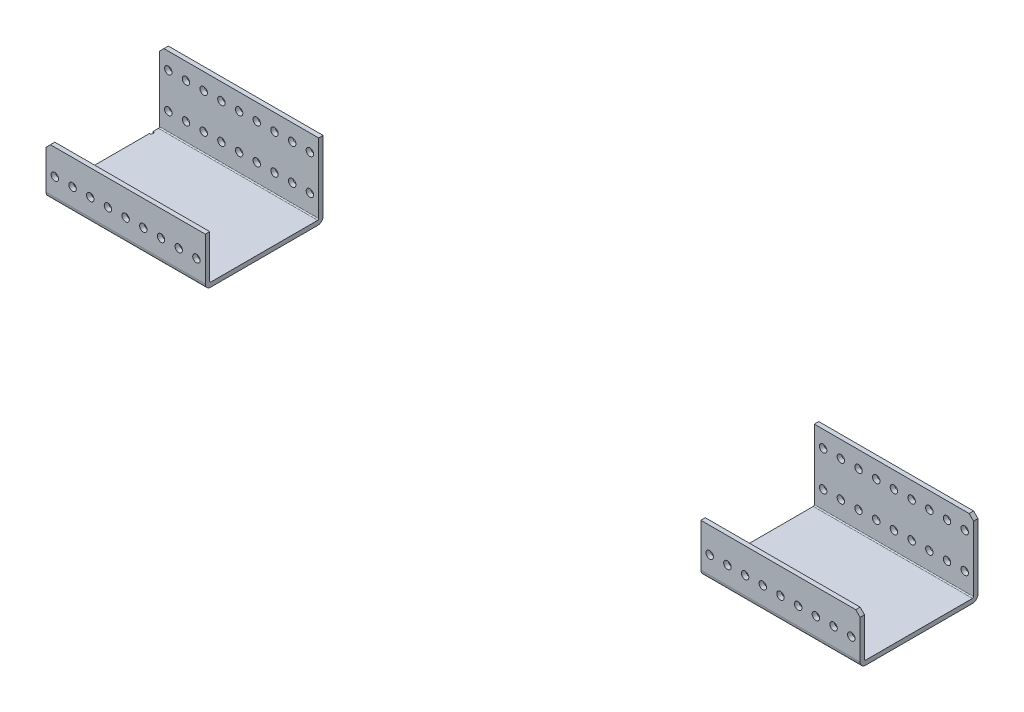
from build123d import *

# Parameters (mm, degrees)
SKETCH1_W                = 584.2
SKETCH1_H                = 84.582
BOSS_EXTRUDE1_DEPTH      = 34.925
SKETCH2_W                = 81.407
SKETCH2_H                = 31.75
CUT_EXTRUDE1_DEPTH       = 585.2
SKETCH3_W                = 584.2
SKETCH3_H                = 3.175
BOSS_EXTRUDE2_DEPTH      = 50.8
M2_CLEARANCE_HOLE1_D     = 2.54
M2_CLEARANCE_HOLE1_DEPTH = 3.175
M5_CLEARANCE_HOLE1_D     = 5.334
M5_CLEARANCE_HOLE1_DEPTH = 84.582
CHAMFER1_SIZE            = 3.175
FILLET1_R                = 0.762
FILLET2_R                = 3.937
SKETCH9_W                = 355.6
SKETCH9_H                = 96.804801105
CUT_EXTRUDE2_DEPTH       = 85.582


with BuildPart() as part:
    # Sketch1 → Boss-Extrude1 (new body)
    with BuildSketch(Plane(origin=(0, 57.816398039, 0), x_dir=(1, 0, 0), z_dir=(0, 1, 0))):
        with Locations((195.998031467, -103.269491579)):
            Rectangle(SKETCH1_W, SKETCH1_H)
    extrude(amount=-BOSS_EXTRUDE1_DEPTH)

    # Sketch2 → Cut-Extrude1 (cut, through all)
    with BuildSketch(Plane(origin=(488.098031467, 0, 0), x_dir=(0, 0, -1), z_dir=(1, 0, 0))):
        with Locations((-101.681991579, 41.941398039)):
            Rectangle(SKETCH2_W, SKETCH2_H)
    extrude(amount=-CUT_EXTRUDE1_DEPTH, mode=Mode.SUBTRACT)

    # Sketch3 → Boss-Extrude2 (add)
    with BuildSketch(Plane(origin=(0, 26.066398039, 0), x_dir=(-1, 0, 0), z_dir=(0, 1, 0))):
        with Locations((-195.998031467, 62.565991579)):
            Rectangle(SKETCH3_W, SKETCH3_H)
    extrude(amount=BOSS_EXTRUDE2_DEPTH)

    # M2 Clearance Hole1
    with Locations(Plane(origin=(0, 26.066398039, 0), x_dir=(1, 0, 0), z_dir=(0, 1, 0))):
        with Locations((-96.101968533, -136.543491579), (-96.101968533, -69.995491579)):
            Hole(M2_CLEARANCE_HOLE1_D / 2, depth=M2_CLEARANCE_HOLE1_DEPTH)

    # M5 Clearance Hole1
    with Locations(Plane(origin=(0, 0, 60.978491579), x_dir=(-1, 0, 0), z_dir=(0, 0, -1))):
        with Locations((-469.048031467, 64.928398039), (-481.748031467, 64.928398039), (-469.048031467, 39.528398039), (-481.748031467, 39.528398039), (-456.348031467, 39.528398039), (-443.648031467, 39.528398039), (-430.948031467, 39.528398039), (-418.248031467, 39.528398039), (-405.548031467, 39.528398039), (-392.848031467, 39.528398039), (-380.148031467, 39.528398039), (-367.448031467, 39.528398039), (-354.748031467, 39.528398039), (-342.048031467, 39.528398039), (-329.348031467, 39.528398039), (-316.648031467, 39.528398039), (-303.948031467, 39.528398039), (-291.248031467, 39.528398039), (-278.548031467, 39.528398039), (-265.848031467, 39.528398039), (-253.148031467, 39.528398039), (-240.448031467, 39.528398039), (-227.748031467, 39.528398039), (-215.048031467, 39.528398039), (-202.348031467, 39.528398039), (-189.648031467, 39.528398039), (-176.948031467, 39.528398039), (-164.248031467, 39.528398039), (-151.548031467, 39.528398039), (-138.848031467, 39.528398039), (-126.148031467, 39.528398039), (-113.448031467, 39.528398039), (-100.748031467, 39.528398039), (-88.048031467, 39.528398039), (-75.348031467, 39.528398039), (-62.648031467, 39.528398039), (-49.948031467, 39.528398039), (-37.248031467, 39.528398039), (-24.548031467, 39.528398039), (-11.848031467, 39.528398039), (0.851968533, 39.528398039), (13.551968533, 39.528398039), (26.251968533, 39.528398039), (38.951968533, 39.528398039), (51.651968533, 39.528398039), (64.351968533, 39.528398039), (77.051968533, 39.528398039), (89.751968533, 39.528398039), (-456.348031467, 64.928398039), (-443.648031467, 64.928398039), (-430.948031467, 64.928398039), (-418.248031467, 64.928398039), (-405.548031467, 64.928398039), (-392.848031467, 64.928398039), (-380.148031467, 64.928398039), (-367.448031467, 64.928398039), (-354.748031467, 64.928398039), (-342.048031467, 64.928398039), (-329.348031467, 64.928398039), (-316.648031467, 64.928398039), (-303.948031467, 64.928398039), (-291.248031467, 64.928398039), (-278.548031467, 64.928398039), (-265.848031467, 64.928398039), (-253.148031467, 64.928398039), (-240.448031467, 64.928398039), (-227.748031467, 64.928398039), (-215.048031467, 64.928398039), (-202.348031467, 64.928398039), (-189.648031467, 64.928398039), (-176.948031467, 64.928398039), (-164.248031467, 64.928398039), (-151.548031467, 64.928398039), (-138.848031467, 64.928398039), (-126.148031467, 64.928398039), (-113.448031467, 64.928398039), (-100.748031467, 64.928398039), (-88.048031467, 64.928398039), (-75.348031467, 64.928398039), (-62.648031467, 64.928398039), (-49.948031467, 64.928398039), (-37.248031467, 64.928398039), (-24.548031467, 64.928398039), (-11.848031467, 64.928398039), (0.851968533, 64.928398039), (13.551968533, 64.928398039), (26.251968533, 64.928398039), (38.951968533, 64.928398039), (51.651968533, 64.928398039), (64.351968533, 64.928398039), (77.051968533, 64.928398039), (89.751968533, 64.928398039)):
            Hole(M5_CLEARANCE_HOLE1_D / 2, depth=M5_CLEARANCE_HOLE1_DEPTH)

    # Chamfer1
    chamfer1_edges = [part.edges().sort_by_distance(p)[0] for p in [
        (-96.101968533, 57.816398039, 143.972991579),
        (-96.101968533, 76.866398039, 62.565991579),
        (488.098031467, 76.866398039, 62.565991579),
        (488.098031467, 57.816398039, 143.972991579),
    ]]
    chamfer(chamfer1_edges, length=CHAMFER1_SIZE)

    # Fillet1
    fillet1_edges = [part.edges().sort_by_distance(p)[0] for p in [
        (195.998031467, 26.066398039, 142.385491579),
        (195.998031467, 26.066398039, 64.153491579),
    ]]
    fillet(fillet1_edges, radius=FILLET1_R)

    # Fillet2
    fillet2_edges = [part.edges().sort_by_distance(p)[0] for p in [
        (195.998031467, 22.891398039, 60.978491579),
        (195.998031467, 22.891398039, 145.560491579),
    ]]
    fillet(fillet2_edges, radius=FILLET2_R)

    # Sketch9 → Cut-Extrude2 (cut, through all)
    with BuildSketch(Plane(origin=(0, 0, 60.978491579), x_dir=(-1, 0, 0), z_dir=(0, 0, -1))):
        with Locations((-195.998031467, 28.463997486)):
            Rectangle(SKETCH9_W, SKETCH9_H)
    extrude(amount=-CUT_EXTRUDE2_DEPTH, mode=Mode.SUBTRACT)


solid = part.part
